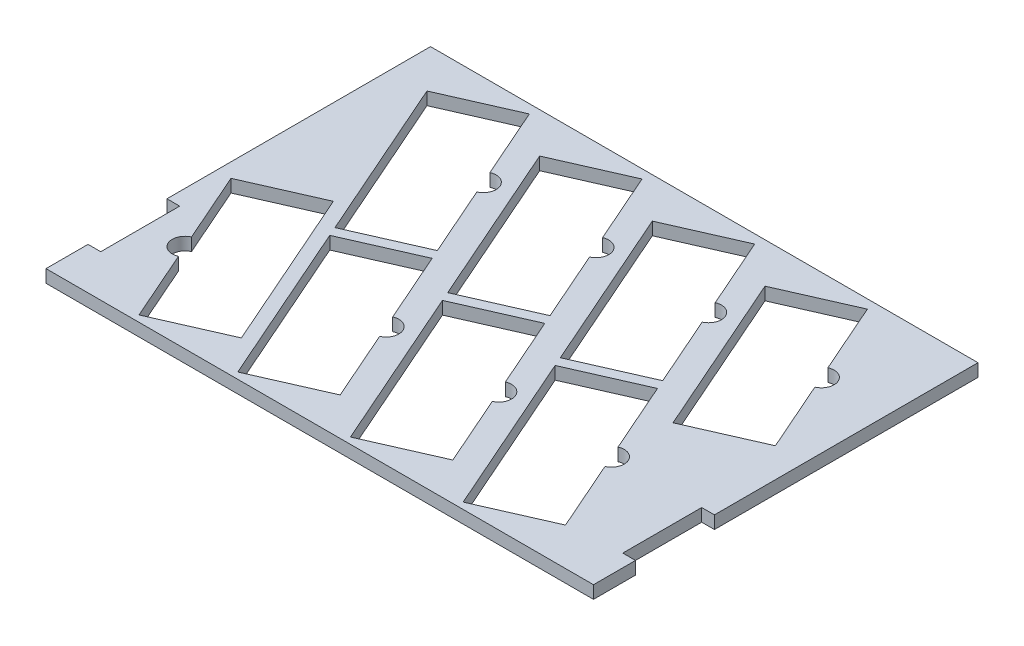
from build123d import *

# Parameters (mm, degrees)
BOSS_EXTRUDE1_DEPTH = 10


with BuildPart() as part:
    # Sketch1 → Boss-Extrude1 (new body)
    with BuildSketch(Plane(origin=(0, 0, 0), x_dir=(1, 0, 0), z_dir=(0, 1, 0))):
        Polygon((-215, -118), (-215, -151), (215, -151), (215, -118), (205, -118), (205, -101), (205, -56), (215, -56), (215, 151), (-215, 151), (-215, -56), (-205, -56), (-205, -101), (-205, -118), align=None)
        with BuildLine():
            Line((-179.385227366, -72.32161442), (-203.75855493, -16.948417804))
            Line((-203.75855493, -16.948417804), (-147.92772859, 7.626342219))
            Line((-147.92772859, 7.626342219), (-91.123775094, -121.425239977))
            Line((-91.123775094, -121.425239977), (-146.954601434, -146))
            Line((-146.954601434, -146), (-171.327928998, -90.626803384))
            ThreePointArc((-171.327928998, -90.626803384), (-184.509172664, -85.502858086), (-179.385227366, -72.32161442))
        make_face(mode=Mode.SUBTRACT)
        with BuildLine():
            Line((-69.380969017, -146), (-126.184922514, -16.948417804))
            Line((-126.184922514, -16.948417804), (-70.354096174, 7.626342219))
            Line((-70.354096174, 7.626342219), (-45.98076861, -47.746854397))
            ThreePointArc((-45.98076861, -47.746854397), (-32.799524944, -52.870799695), (-37.923470242, -66.052043361))
            Line((-37.923470242, -66.052043361), (-13.550142678, -121.425239977))
            Line((-13.550142678, -121.425239977), (-69.380969017, -146))
        make_face(mode=Mode.SUBTRACT)
        with BuildLine():
            Line((19.11852712, -146), (-37.685426377, -16.948417804))
            Line((-37.685426377, -16.948417804), (18.145399963, 7.626342219))
            Line((18.145399963, 7.626342219), (42.518727527, -47.746854397))
            ThreePointArc((42.518727527, -47.746854397), (55.699971193, -52.870799695), (50.576025895, -66.052043361))
            Line((50.576025895, -66.052043361), (74.94935346, -121.425239977))
            Line((74.94935346, -121.425239977), (19.11852712, -146))
        make_face(mode=Mode.SUBTRACT)
        with BuildLine():
            Line((107.618023257, -146), (50.81406976, -16.948417804))
            Line((50.81406976, -16.948417804), (106.6448961, 7.626342219))
            Line((106.6448961, 7.626342219), (131.018223664, -47.746854397))
            ThreePointArc((131.018223664, -47.746854397), (144.19946733, -52.870799695), (139.075522033, -66.052043361))
            Line((139.075522033, -66.052043361), (163.448849597, -121.425239977))
            Line((163.448849597, -121.425239977), (107.618023257, -146))
        make_face(mode=Mode.SUBTRACT)
        with BuildLine():
            Line((-129.407841861, -9.626342219), (-186.211795357, 119.425239977))
            Line((-186.211795357, 119.425239977), (-130.380969017, 144))
            Line((-130.380969017, 144), (-106.007641453, 88.626803384))
            ThreePointArc((-106.007641453, 88.626803384), (-92.826397787, 83.502858086), (-97.950343085, 70.32161442))
            Line((-97.950343085, 70.32161442), (-73.577015521, 14.948417804))
            Line((-73.577015521, 14.948417804), (-129.407841861, -9.626342219))
        make_face(mode=Mode.SUBTRACT)
        with BuildLine():
            Line((-40.908345724, -9.626342219), (-97.71229922, 119.425239977))
            Line((-97.71229922, 119.425239977), (-41.88147288, 144))
            Line((-41.88147288, 144), (-17.508145316, 88.626803384))
            ThreePointArc((-17.508145316, 88.626803384), (-4.32690165, 83.502858086), (-9.450846948, 70.32161442))
            Line((-9.450846948, 70.32161442), (14.922480616, 14.948417804))
            Line((14.922480616, 14.948417804), (-40.908345724, -9.626342219))
        make_face(mode=Mode.SUBTRACT)
        with BuildLine():
            Line((47.591150413, -9.626342219), (-9.212803083, 119.425239977))
            Line((-9.212803083, 119.425239977), (46.618023257, 144))
            Line((46.618023257, 144), (70.991350821, 88.626803384))
            ThreePointArc((70.991350821, 88.626803384), (84.172594487, 83.502858086), (79.048649189, 70.32161442))
            Line((79.048649189, 70.32161442), (103.421976753, 14.948417804))
            Line((103.421976753, 14.948417804), (47.591150413, -9.626342219))
        make_face(mode=Mode.SUBTRACT)
        with BuildLine():
            Line((136.09064655, -9.626342219), (79.286693054, 119.425239977))
            Line((79.286693054, 119.425239977), (135.117519394, 144))
            Line((135.117519394, 144), (159.490846958, 88.626803384))
            ThreePointArc((159.490846958, 88.626803384), (172.672090624, 83.502858086), (167.548145326, 70.32161442))
            Line((167.548145326, 70.32161442), (191.92147289, 14.948417804))
            Line((191.92147289, 14.948417804), (136.09064655, -9.626342219))
        make_face(mode=Mode.SUBTRACT)
    extrude(amount=-BOSS_EXTRUDE1_DEPTH)


solid = part.part
